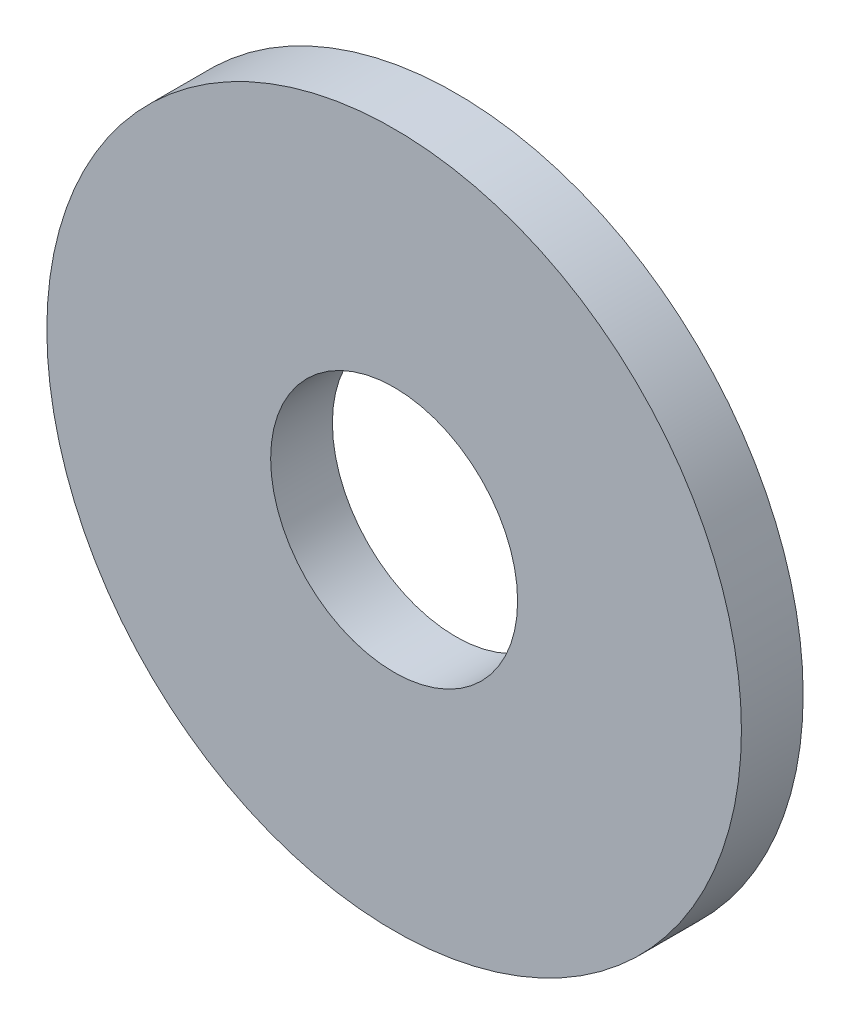
from build123d import *

# Parameters (mm, degrees)
SKETCH2_R           = 4.5
SKETCH2_R_2         = 1.6
BOSS_EXTRUDE1_DEPTH = 0.4


with BuildPart() as part:
    # Sketch2 → Boss-Extrude1 (new, symmetric)
    with BuildSketch(Plane.XY):
        Circle(SKETCH2_R)
        Circle(SKETCH2_R_2, mode=Mode.SUBTRACT)
    extrude(amount=BOSS_EXTRUDE1_DEPTH, both=True)


solid = part.part
